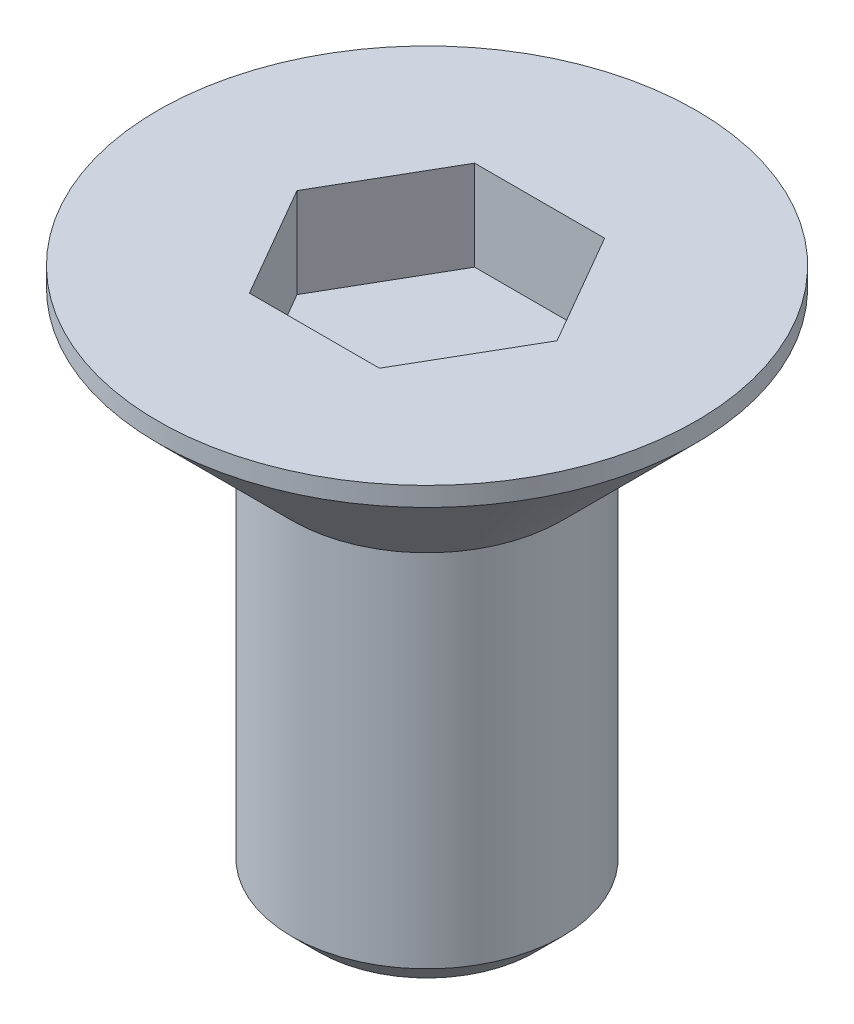
from build123d import *

# Parameters (mm, degrees)
CHAFL_N2_SIZE         = 0.3
CHAFL_N2_SIZE2        = 0.212132034
CHAFL_N3_SIZE         = 0.3
CORTAR_EXTRUIR2_DEPTH = 1


with BuildPart() as part:
    # Croquis1 → Revolución1 (revolve)
    with BuildSketch(Plane.XY, mode=Mode.PRIVATE) as revoluci_n1_sk:
        Polygon((0, 0), (3.2, 0), (1.5, -1.7), (1.5, -6), (0, -6), align=None)
    revolve(revoluci_n1_sk.sketch.rotate(Axis((0, 0, 0), (0, -1, 0)), 90), axis=Axis((0, 0, 0), (0, -1, 0)))

    # Chaflán2
    chafl_n2_edges = [part.edges().sort_by_distance(p)[0] for p in [
        (0, 0, -3.2),
    ]]
    chafl_n2_side = [part.faces().sort_by_distance(p)[0] for p in [
        (0, -0.85, -2.35),
    ]]
    chamfer(chafl_n2_edges, length=CHAFL_N2_SIZE, length2=CHAFL_N2_SIZE2, reference=chafl_n2_side[0])

    # Chaflán3
    chafl_n3_edges = [part.edges().sort_by_distance(p)[0] for p in [
        (0, -6, -1.5),
    ]]
    chamfer(chafl_n3_edges, length=CHAFL_N3_SIZE)

    # Croquis3 → Cortar-Extruir2 (cut)
    with BuildSketch(Plane(origin=(0, 0, 0), x_dir=(1, 0, 0), z_dir=(0, 1, 0))):
        Polygon((-0.721687836, 1.25), (-1.443375673, 0), (-0.721687836, -1.25), (0.721687836, -1.25), (1.443375673, 0), (0.721687836, 1.25), align=None)
    extrude(amount=-CORTAR_EXTRUIR2_DEPTH, mode=Mode.SUBTRACT)


solid = part.part
